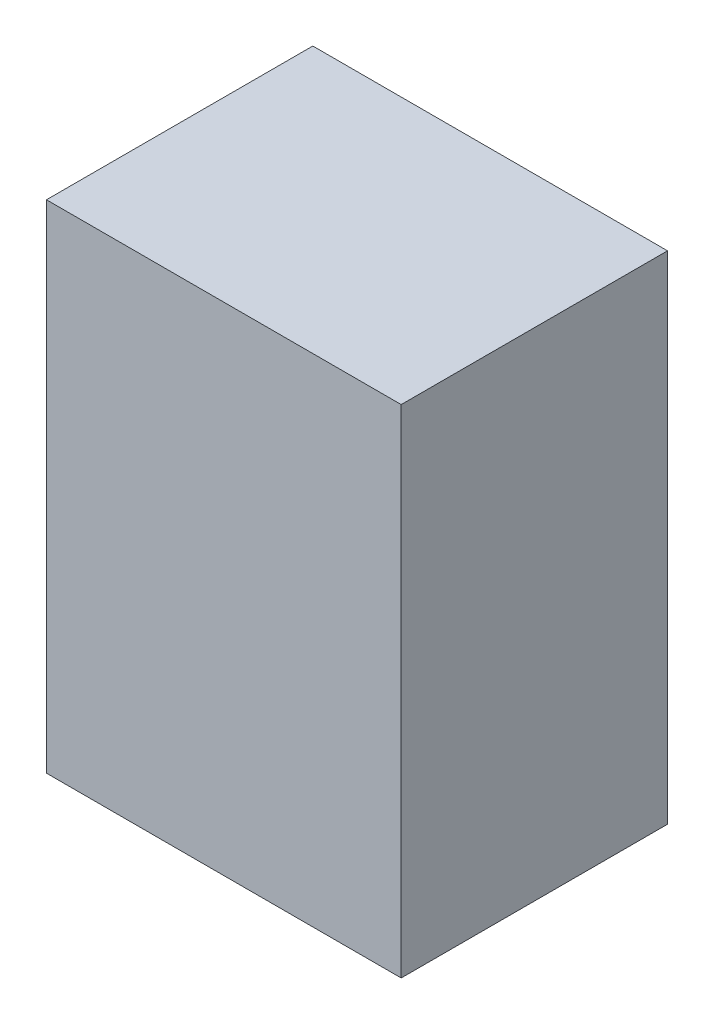
from build123d import *

# Parameters (mm, degrees)
SKETCH_1_W      = 25
SKETCH_1_H      = 35
EXTRUDE_1_DEPTH = 18.77


with BuildPart() as part:
    # 草图1 → 凸台-拉伸1 (new body)
    with BuildSketch(Plane.XY):
        Rectangle(SKETCH_1_W, SKETCH_1_H)
    extrude(amount=EXTRUDE_1_DEPTH)


solid = part.part
